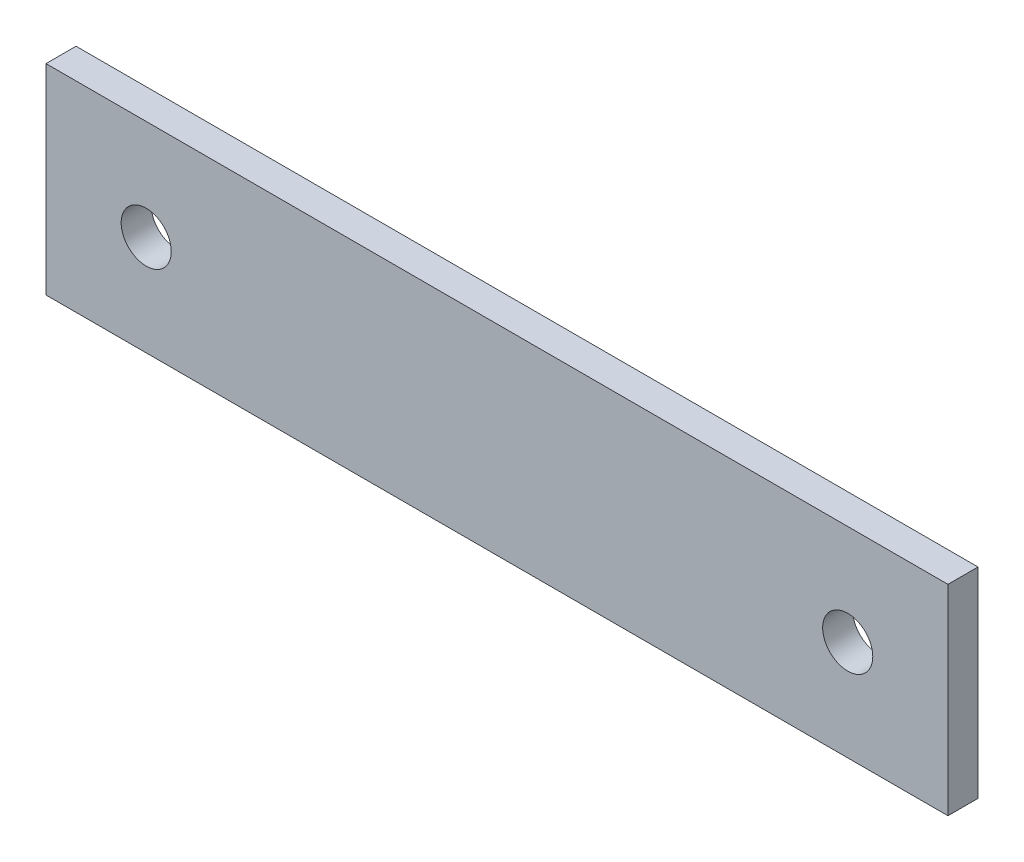
from build123d import *

# Parameters (mm, degrees)
SKETCH1_W           = 90
SKETCH1_H           = 20
SKETCH1_R           = 2.5
BOSS_EXTRUDE1_DEPTH = 3


with BuildPart() as part:
    # Sketch1 → Boss-Extrude1 (new body)
    with BuildSketch(Plane.XY):
        with Locations((45, 10)):
            Rectangle(SKETCH1_W, SKETCH1_H)
        with Locations((10, 10)):
            Circle(SKETCH1_R, mode=Mode.SUBTRACT)
        with Locations((80, 10)):
            Circle(SKETCH1_R, mode=Mode.SUBTRACT)
    extrude(amount=BOSS_EXTRUDE1_DEPTH)


solid = part.part
